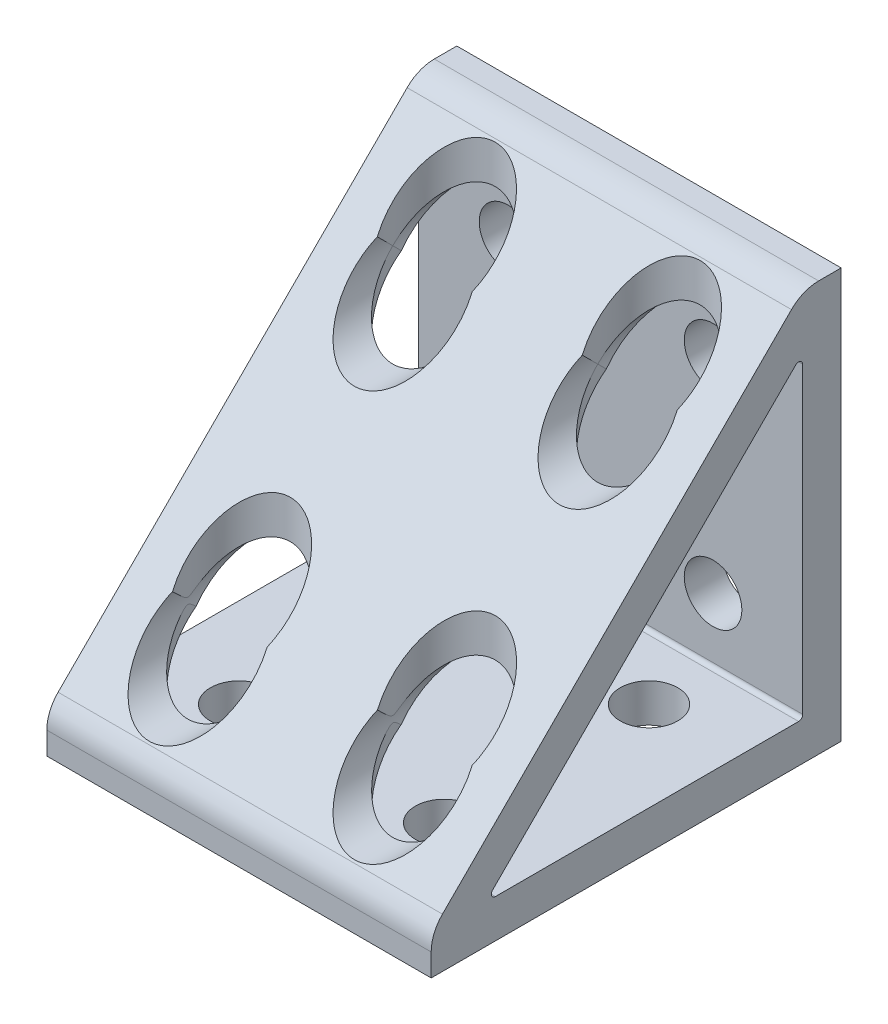
from build123d import *

# Parameters (mm, degrees)
BOSS_EXTRUDE1_DEPTH               = 23.8125
K_0_281_DIAMETER_HOLE3_AT_2_COUNT = 2
K_0_281_DIAMETER_HOLE3_AT_2_PITCH = 25.4
SKETCH18_R                        = 6.35
CUT_EXTRUDE15_DEPTH               = 73.574972012
SKETCH19_R                        = 6.35
CUT_EXTRUDE16_DEPTH               = 27.94
K_0_281_DIAMETER_HOLE4_AT_2_COUNT = 2
K_0_281_DIAMETER_HOLE4_AT_2_PITCH = 25.4
SKETCH22_R                        = 6.35
CUT_EXTRUDE17_DEPTH               = 50.8
SKETCH23_R                        = 6.35
CUT_EXTRUDE18_DEPTH               = 50.8
LPATTERN2_COUNT                   = 2
LPATTERN2_PITCH                   = 25.4


with BuildPart() as part:
    # Sketch1 → Boss-Extrude1 (new, symmetric)
    with BuildSketch(Plane(origin=(0, 0, 0), x_dir=(0, 0, -1), z_dir=(1, 0, 0))):
        with BuildLine():
            Line((-6.157403955, 49.405096045), (-49.405096045, 6.157403955))
            ThreePointArc((-49.405096045, 6.157403955), (-50.437476274, 4.612337756), (-50.8, 2.789807909))
            Line((-50.8, 2.789807909), (-50.8, 0))
            Line((-50.8, 0), (0, 0))
            Line((0, 0), (0, 50.8))
            Line((0, 50.8), (-2.789807909, 50.8))
            ThreePointArc((-2.789807909, 50.8), (-4.612337756, 50.437476274), (-6.157403955, 49.405096045))
        make_face()
        with BuildLine():
            Line((-4.7625, 5.2705), (-4.7625, 42.83838742))
            ThreePointArc((-4.7625, 42.83838742), (-5.076096816, 43.307718222), (-5.629710245, 43.197597664))
            Line((-5.629710245, 43.197597664), (-43.197597664, 5.629710245))
            ThreePointArc((-43.197597664, 5.629710245), (-43.307718222, 5.076096816), (-42.83838742, 4.7625))
            Line((-42.83838742, 4.7625), (-5.2705, 4.7625))
            ThreePointArc((-5.2705, 4.7625), (-4.911289755, 4.911289755), (-4.7625, 5.2705))
        make_face(mode=Mode.SUBTRACT)
    extrude(amount=BOSS_EXTRUDE1_DEPTH, both=True)

    # Sketch14 → K (0.281) Diameter Hole3 (revolve, cut)
    with BuildSketch(Plane(origin=(12.7, 12.7, 0), x_dir=(0, 1, 0), z_dir=(1, 0, 0))):
        Polygon((0, 0), (0, 8.748291291), (3.5687, 6.604), (3.5687, 0), align=None)
    k_0_281_diameter_hole3 = revolve(axis=Axis((12.7, 12.7, -6.35), (0, 0, 1)), mode=Mode.SUBTRACT)

    # K (0.281) Diameter Hole3 at 2: K (0.281) Diameter Hole3 ×2
    with Locations(*[(0, i * K_0_281_DIAMETER_HOLE3_AT_2_PITCH, 0) for i in range(1, K_0_281_DIAMETER_HOLE3_AT_2_COUNT)]):
        add(k_0_281_diameter_hole3, mode=Mode.SUBTRACT)

    # Sketch18 → Cut-Extrude15 (cut, through all)
    with BuildSketch(Plane.XY.offset(4.7625)):
        with Locations(Location((12.7, 12.7, 0), (0, 0, 90))):
            Circle(SKETCH18_R)
    cut_extrude15 = extrude(amount=CUT_EXTRUDE15_DEPTH, mode=Mode.SUBTRACT)

    # Sketch19 → Cut-Extrude16 (cut)
    with BuildSketch(Plane.XY.offset(4.7625)):
        with Locations(Location((12.7, 38.1, 0), (0, 0, 131.737490268))):
            Circle(SKETCH19_R)
    cut_extrude16 = extrude(amount=CUT_EXTRUDE16_DEPTH, mode=Mode.SUBTRACT)

    # Sketch20 → K (0.281) Diameter Hole4 (revolve, cut)
    with BuildSketch(Plane(origin=(12.7, 0, 12.7), x_dir=(0, 0, -1), z_dir=(1, 0, 0))):
        Polygon((0, 0), (0, 8.748291291), (3.5687, 6.604), (3.5687, 0), align=None)
    k_0_281_diameter_hole4 = revolve(axis=Axis((12.7, -6.35, 12.7), (0, 1, 0)), mode=Mode.SUBTRACT)

    # K (0.281) Diameter Hole4 at 2: K (0.281) Diameter Hole4 ×2
    with Locations(*[Vector(0.0004999999999999537, 0, 0.9999998749999922) * (i * K_0_281_DIAMETER_HOLE4_AT_2_PITCH) for i in range(1, K_0_281_DIAMETER_HOLE4_AT_2_COUNT)]):
        add(k_0_281_diameter_hole4, mode=Mode.SUBTRACT)

    # Sketch22 → Cut-Extrude17 (cut)
    with BuildSketch(Plane(origin=(0, 4.7625, 0), x_dir=(1, 0, 0), z_dir=(0, 1, 0))):
        with Locations((12.7, -12.7)):
            Circle(SKETCH22_R)
    cut_extrude17 = extrude(amount=CUT_EXTRUDE17_DEPTH, mode=Mode.SUBTRACT)

    # Sketch23 → Cut-Extrude18 (cut)
    with BuildSketch(Plane(origin=(0, 4.7625, 0), x_dir=(1, 0, 0), z_dir=(0, 1, 0))):
        with Locations((12.7127, -38.099996825)):
            Circle(SKETCH23_R)
    cut_extrude18 = extrude(amount=CUT_EXTRUDE18_DEPTH, mode=Mode.SUBTRACT)

    # LPattern2: K (0.281) Diameter Hole3, Cut-Extrude15, Cut-Extrude16, K (0.281) Diameter Hole4, Cut-Extrude17, Cut-Extrude18 ×2
    with Locations(*[(-i * LPATTERN2_PITCH, 0, 0) for i in range(1, LPATTERN2_COUNT)]):
        add(k_0_281_diameter_hole3, mode=Mode.SUBTRACT)
        add(cut_extrude15, mode=Mode.SUBTRACT)
        add(cut_extrude16, mode=Mode.SUBTRACT)
        add(k_0_281_diameter_hole4, mode=Mode.SUBTRACT)
        add(cut_extrude17, mode=Mode.SUBTRACT)
        add(cut_extrude18, mode=Mode.SUBTRACT)

    # LPattern2 copy 1 sketch → LPattern2 copy 1 (revolve, cut)
    with BuildSketch(Plane(origin=(-12.7, 38.1, 0), x_dir=(0, 1, 0), z_dir=(1, 0, 0))):
        Polygon((0, 0), (0, 8.748291291), (3.5687, 6.604), (3.5687, 0), align=None)
    revolve(axis=Axis((-12.7, 38.1, -6.35), (0, 0, 1)), mode=Mode.SUBTRACT)

    # LPattern2 copy 2 sketch → LPattern2 copy 2 (revolve, cut)
    with BuildSketch(Plane(origin=(-12.6873, 0, 38.099996825), x_dir=(0, 0, -1), z_dir=(1, 0, 0))):
        Polygon((0, 0), (0, 8.748291291), (3.5687, 6.604), (3.5687, 0), align=None)
    revolve(axis=Axis((-12.6873, -6.35, 38.099996825), (0, 1, 0)), mode=Mode.SUBTRACT)


solid = part.part
